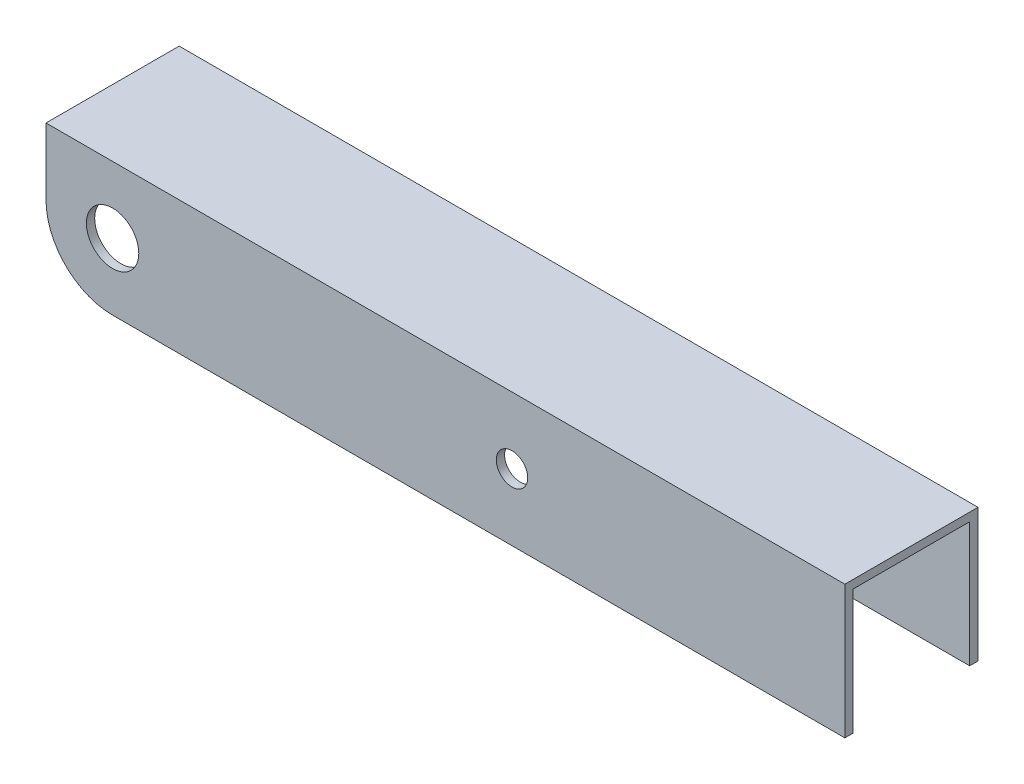
from build123d import *

# Parameters (mm, degrees)
SKETCH1_W           = 25.4
SKETCH1_H           = 50.8
SKETCH1_W_2         = 22.225
SKETCH1_H_2         = 47.625
BOSS_EXTRUDE1_DEPTH = 152.4
SKETCH2_R           = 5
SKETCH2_R_2         = 3
CUT_EXTRUDE1_DEPTH  = 152.4


with BuildPart() as part:
    # Sketch1 → Boss-Extrude1 (new body)
    with BuildSketch(Plane(origin=(0, 0, 0), x_dir=(0, 0, -1), z_dir=(1, 0, 0))):
        with Locations((12.7, 25.4)):
            Rectangle(SKETCH1_W, SKETCH1_H)
        with Locations((12.7, 25.4)):
            Rectangle(SKETCH1_W_2, SKETCH1_H_2, mode=Mode.SUBTRACT)
    extrude(amount=BOSS_EXTRUDE1_DEPTH)

    # Sketch2 → Cut-Extrude1 (cut)
    with BuildSketch(Plane.XY):
        with Locations((12.7, 38.1)):
            Circle(SKETCH2_R)
        with Locations((88.9, 38.1)):
            Circle(SKETCH2_R_2)
        with BuildLine():
            Line((12.7, 25.4), (152.4, 25.4))
            Line((152.4, 25.4), (152.4, 0))
            Line((152.4, 0), (0, 0))
            Line((0, 0), (0, 38.1))
            ThreePointArc((0, 38.1), (3.719743879, 29.119743879), (12.7, 25.4))
        make_face()
    extrude(amount=-CUT_EXTRUDE1_DEPTH, mode=Mode.SUBTRACT)


solid = part.part
